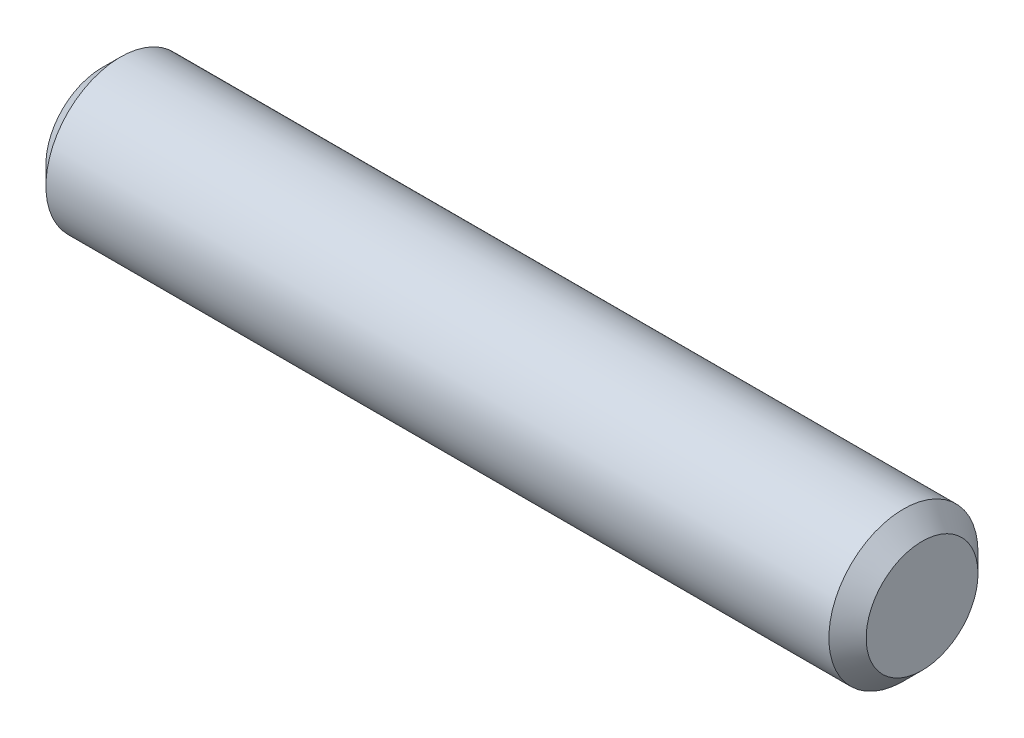
from build123d import *

# Parameters (mm, degrees)
SKETCH1_R           = 2
BOSS_EXTRUDE1_DEPTH = 11
CHAMFER1_SIZE       = 0.5


with BuildPart() as part:
    # Sketch1 → Boss-Extrude1 (new body, symmetric)
    with BuildSketch(Plane(origin=(0, 0, 0), x_dir=(0, 0, -1), z_dir=(1, 0, 0))):
        Circle(SKETCH1_R)
    extrude(amount=BOSS_EXTRUDE1_DEPTH, both=True)

    # Chamfer1
    chamfer1_edges = [part.edges().sort_by_distance(p)[0] for p in [
        (-11, 0, 2),
        (11, 0, 2),
    ]]
    chamfer(chamfer1_edges, length=CHAMFER1_SIZE)


solid = part.part
